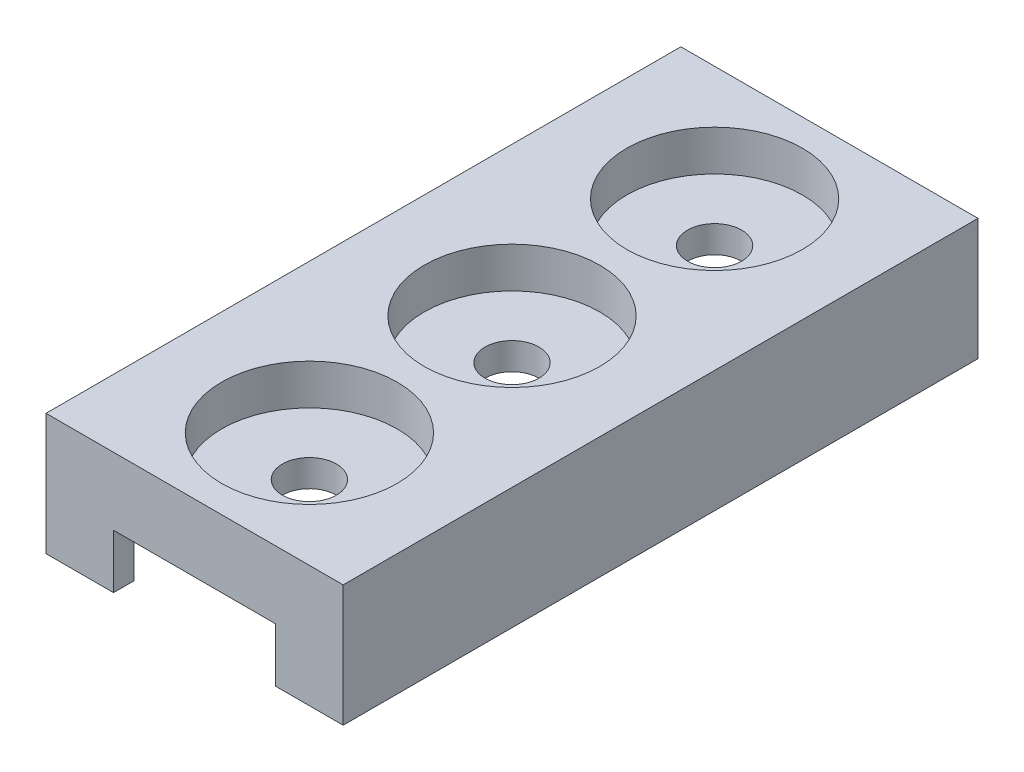
from build123d import *

# Parameters (mm, degrees)
SKETCH2_W           = 22
SKETCH2_H           = 47
SKETCH2_R           = 6.5
BOSS_EXTRUDE1_DEPTH = 3
SKETCH3_W           = 22
SKETCH3_H           = 47
BOSS_EXTRUDE2_DEPTH = 2
BOSS_EXTRUDE3_DEPTH = 4
SKETCH5_5_R         = 2
BOSS_EXTRUDE6_DEPTH = 1
SKETCH5_6_R         = 2
CUT_EXTRUDE1_DEPTH  = 2
SKETCH5_7_W         = 3
SKETCH5_7_H         = 1.5
BOSS_EXTRUDE7_DEPTH = 4


with BuildPart() as part:
    # Sketch2 → Boss-Extrude1 (new body)
    with BuildSketch(Plane(origin=(0, 0, 0), x_dir=(1, 0, 0), z_dir=(0, 1, 0))):
        Rectangle(SKETCH2_W, SKETCH2_H)
        with Locations((0, -15)):
            Circle(SKETCH2_R, mode=Mode.SUBTRACT)
        Circle(SKETCH2_R, mode=Mode.SUBTRACT)
        with Locations((0, 15)):
            Circle(SKETCH2_R, mode=Mode.SUBTRACT)
    extrude(amount=BOSS_EXTRUDE1_DEPTH)

    # Sketch3 → Boss-Extrude2 (add)
    with BuildSketch(Plane.XZ):
        Rectangle(SKETCH3_W, SKETCH3_H)
    extrude(amount=BOSS_EXTRUDE2_DEPTH)

    # Sketch5 → Boss-Extrude3 (add)
    with BuildSketch(Plane(origin=(0, -2, 0), x_dir=(-1, 0, 0), z_dir=(0, -1, 0))):
        Polygon((9, 22), (9, -22), (9, -23.5), (11, -23.5), (11, 23.5), (-11, 23.5), (-11, -23.5), (-9, -23.5), (-9, -22), (-9, 22), align=None)
    extrude(amount=BOSS_EXTRUDE3_DEPTH)

    # Sketch5_5 → Boss-Extrude6 (add)
    with BuildSketch(Plane(origin=(0, -2, 0), x_dir=(-1, 0, 0), z_dir=(0, -1, 0))):
        Circle(SKETCH5_5_R)
    extrude(amount=-BOSS_EXTRUDE6_DEPTH)

    # Sketch5_6 → Cut-Extrude1 (cut)
    with BuildSketch(Plane(origin=(0, -2, 0), x_dir=(-1, 0, 0), z_dir=(0, -1, 0))):
        with Locations((0, -15)):
            Circle(SKETCH5_6_R)
        with Locations((0, 15)):
            Circle(SKETCH5_6_R)
        Circle(SKETCH5_6_R)
    extrude(amount=-CUT_EXTRUDE1_DEPTH, mode=Mode.SUBTRACT)

    # Sketch5_7 → Boss-Extrude7 (add)
    with BuildSketch(Plane(origin=(0, -2, 0), x_dir=(-1, 0, 0), z_dir=(0, -1, 0))):
        with Locations((7.5, -22.75)):
            Rectangle(SKETCH5_7_W, SKETCH5_7_H)
        with Locations((-7.5, -22.75)):
            Rectangle(SKETCH5_7_W, SKETCH5_7_H)
    extrude(amount=BOSS_EXTRUDE7_DEPTH)


solid = part.part
